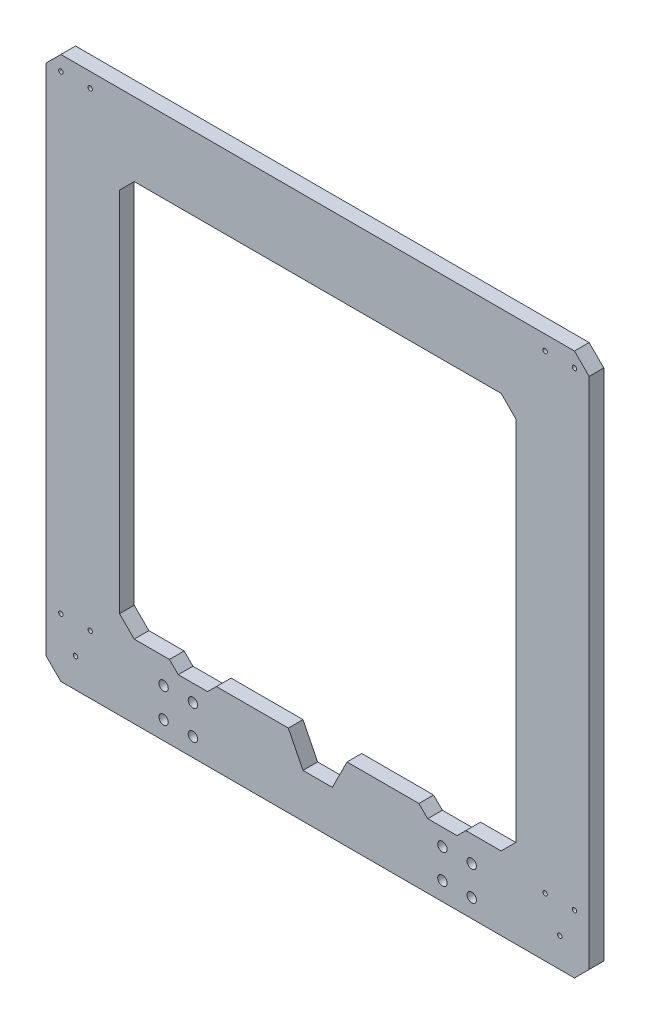
from build123d import *

# Parameters (mm, degrees)
SKETCH1_W           = 370
SKETCH1_H           = 370
SKETCH1_R           = 3.2
SKETCH1_R_2         = 1.5
BOSS_EXTRUDE1_DEPTH = 10
CHAMFER1_SIZE       = 10
CUT_EXTRUDE1_DEPTH  = 10


with BuildPart() as part:
    # Sketch1 → Boss-Extrude1 (new body)
    with BuildSketch(Plane.XY):
        Rectangle(SKETCH1_W, SKETCH1_H)
        with Locations((85, -152.5)):
            Circle(SKETCH1_R, mode=Mode.SUBTRACT)
        with Locations((85, -172.5)):
            Circle(SKETCH1_R, mode=Mode.SUBTRACT)
        with Locations((105, -152.5)):
            Circle(SKETCH1_R, mode=Mode.SUBTRACT)
        with Locations((105, -172.5)):
            Circle(SKETCH1_R, mode=Mode.SUBTRACT)
        with Locations((-105, -172.5)):
            Circle(SKETCH1_R, mode=Mode.SUBTRACT)
        with Locations((-105, -152.5)):
            Circle(SKETCH1_R, mode=Mode.SUBTRACT)
        with Locations((-85, -172.5)):
            Circle(SKETCH1_R, mode=Mode.SUBTRACT)
        with Locations((-85, -152.5)):
            Circle(SKETCH1_R, mode=Mode.SUBTRACT)
        with Locations((155, -145)):
            Circle(SKETCH1_R_2, mode=Mode.SUBTRACT)
        with Locations((175, -145)):
            Circle(SKETCH1_R_2, mode=Mode.SUBTRACT)
        with Locations((165, -165)):
            Circle(SKETCH1_R_2, mode=Mode.SUBTRACT)
        with Locations((-155, -145)):
            Circle(SKETCH1_R_2, mode=Mode.SUBTRACT)
        with Locations((-175, -145)):
            Circle(SKETCH1_R_2, mode=Mode.SUBTRACT)
        with Locations((-165, -165)):
            Circle(SKETCH1_R_2, mode=Mode.SUBTRACT)
        with Locations((155, 175)):
            Circle(SKETCH1_R_2, mode=Mode.SUBTRACT)
        with Locations((175, 175)):
            Circle(SKETCH1_R_2, mode=Mode.SUBTRACT)
        with Locations((-155, 175)):
            Circle(SKETCH1_R_2, mode=Mode.SUBTRACT)
        with Locations((-175, 175)):
            Circle(SKETCH1_R_2, mode=Mode.SUBTRACT)
        Polygon((-135, 135), (135, 135), (135, -135), (20, -135), (10, -155), (-10, -155), (-20, -135), (-135, -135), align=None, mode=Mode.SUBTRACT)
    extrude(amount=BOSS_EXTRUDE1_DEPTH)

    # Chamfer1
    chamfer1_edges = [part.edges().sort_by_distance(p)[0] for p in [
        (135, -135, 5),
        (135, 135, 5),
        (-135, 135, 5),
        (-135, -135, 5),
        (-185, -185, 5),
        (-185, 185, 5),
        (185, 185, 5),
        (185, -185, 5),
    ]]
    chamfer(chamfer1_edges, length=CHAMFER1_SIZE)

    # Sketch2 → Cut-Extrude1 (cut)
    with BuildSketch(Plane.XY.offset(10)):
        Polygon((-101, -135), (-95, -141), (-75, -141), (-69, -135), align=None)
        Polygon((75, -141), (69, -135), (101, -135), (95, -141), align=None)
    extrude(amount=-CUT_EXTRUDE1_DEPTH, mode=Mode.SUBTRACT)


solid = part.part
